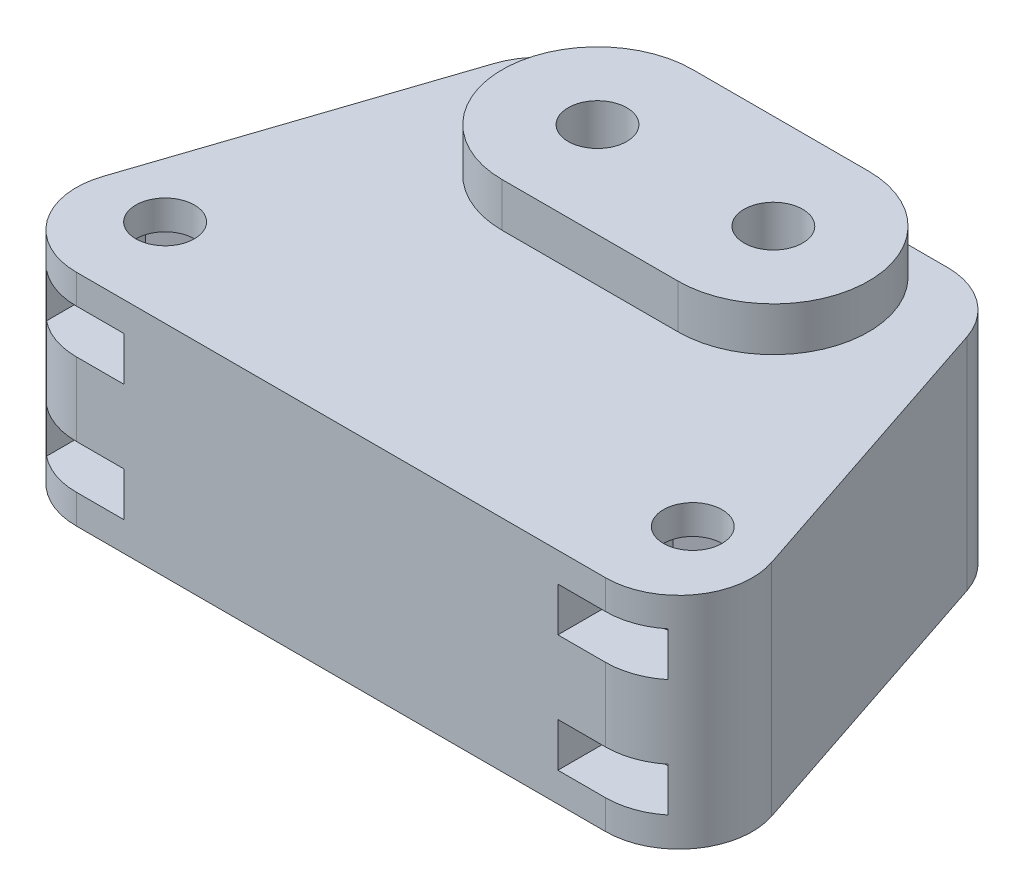
from build123d import *

# Parameters (mm, degrees)
SKETCH1_R           = 2
BOSS_EXTRUDE1_DEPTH = 15
SKETCH2_R           = 2
BOSS_EXTRUDE2_DEPTH = 3
SKETCH5_W           = 6.4
SKETCH5_H           = 3
CUT_EXTRUDE1_DEPTH  = 6.4
CUT_EXTRUDE2_DEPTH  = 3
CUT_EXTRUDE3_DEPTH  = 3
SKETCH8_W           = 6.4
SKETCH8_H           = 3
CUT_EXTRUDE4_DEPTH  = 6
CUT_EXTRUDE5_DEPTH  = 3
CUT_EXTRUDE6_DEPTH  = 3


with BuildPart() as part:
    # Sketch1 → Boss-Extrude1 (new body)
    with BuildSketch(Plane(origin=(0, 0, 0), x_dir=(1, 0, 0), z_dir=(0, 1, 0))):
        with BuildLine():
            Line((-18.062870566, 0), (18.062870566, 0))
            ThreePointArc((18.062870566, 0), (22.119081492, 2.076448577), (22.806287057, 6.58113883))
            Line((22.806287057, 6.58113883), (16.13962039, 26.58113883))
            ThreePointArc((16.13962039, 26.58113883), (14.319755323, 29.056210926), (11.3962039, 30))
            Line((11.3962039, 30), (-11.3962039, 30))
            ThreePointArc((-11.3962039, 30), (-14.319755323, 29.056210926), (-16.13962039, 26.58113883))
            Line((-16.13962039, 26.58113883), (-22.806287057, 6.58113883))
            ThreePointArc((-22.806287057, 6.58113883), (-22.119081492, 2.076448577), (-18.062870566, 0))
        make_face()
        with Locations((-18, 6)):
            Circle(SKETCH1_R, mode=Mode.SUBTRACT)
        with Locations((18, 6)):
            Circle(SKETCH1_R, mode=Mode.SUBTRACT)
        with Locations((6, 23.5)):
            Circle(SKETCH1_R, mode=Mode.SUBTRACT)
        with Locations((-6, 23.5)):
            Circle(SKETCH1_R, mode=Mode.SUBTRACT)
    extrude(amount=BOSS_EXTRUDE1_DEPTH)

    # Sketch2 → Boss-Extrude2 (add)
    with BuildSketch(Plane(origin=(0, 15, 0), x_dir=(1, 0, 0), z_dir=(0, 1, 0))):
        with BuildLine():
            Line((-6, 30), (6, 30))
            ThreePointArc((6, 30), (12.5, 23.5), (6, 17))
            Line((6, 17), (-6, 17))
            ThreePointArc((-6, 17), (-12.5, 23.5), (-6, 30))
        make_face()
        with Locations((-6, 23.5)):
            Circle(SKETCH2_R, mode=Mode.SUBTRACT)
        with Locations((6, 23.5)):
            Circle(SKETCH2_R, mode=Mode.SUBTRACT)
    extrude(amount=BOSS_EXTRUDE2_DEPTH)

    # Sketch5 → Cut-Extrude1 (cut)
    with BuildSketch(Plane(origin=(0, 0, -30), x_dir=(-1, 0, 0), z_dir=(0, 0, -1))):
        with Locations((6, 12.5)):
            Rectangle(SKETCH5_W, SKETCH5_H)
        with Locations((-6, 12.5)):
            Rectangle(SKETCH5_W, SKETCH5_H)
        with Locations((-6, 3.5)):
            Rectangle(SKETCH5_W, SKETCH5_H)
        with Locations((6, 3.5)):
            Rectangle(SKETCH5_W, SKETCH5_H)
    extrude(amount=-CUT_EXTRUDE1_DEPTH, mode=Mode.SUBTRACT)

    # Sketch6 → Cut-Extrude2 (cut)
    with BuildSketch(Plane(origin=(0, 11, 0), x_dir=(1, 0, 0), z_dir=(0, 1, 0))):
        Polygon((9.2, 25.347520861), (6, 27.195041723), (2.8, 25.347520861), (2.8, 21.652479139), (6, 19.804958277), (9.2, 21.652479139), align=None)
        Polygon((-2.8, 25.347520861), (-6, 27.195041723), (-9.2, 25.347520861), (-9.2, 21.652479139), (-6, 19.804958277), (-2.8, 21.652479139), align=None)
    extrude(amount=CUT_EXTRUDE2_DEPTH, mode=Mode.SUBTRACT)

    # Sketch7 → Cut-Extrude3 (cut)
    with BuildSketch(Plane(origin=(0, 2, 0), x_dir=(1, 0, 0), z_dir=(0, 1, 0))):
        Polygon((9.2, 25.347520861), (6, 27.195041723), (2.8, 25.347520861), (2.8, 21.652479139), (6, 19.804958277), (9.2, 21.652479139), align=None)
        Polygon((-6, 19.804958277), (-2.8, 21.652479139), (-2.8, 25.347520861), (-6, 27.195041723), (-9.2, 25.347520861), (-9.2, 21.652479139), align=None)
    extrude(amount=CUT_EXTRUDE3_DEPTH, mode=Mode.SUBTRACT)

    # Sketch8 → Cut-Extrude4 (cut)
    with BuildSketch(Plane.XY):
        with Locations((18, 11.5)):
            Rectangle(SKETCH8_W, SKETCH8_H)
        with Locations((-18, 11.5)):
            Rectangle(SKETCH8_W, SKETCH8_H)
        with Locations((-18, 3.5)):
            Rectangle(SKETCH8_W, SKETCH8_H)
        with Locations((18, 3.5)):
            Rectangle(SKETCH8_W, SKETCH8_H)
    extrude(amount=-CUT_EXTRUDE4_DEPTH, mode=Mode.SUBTRACT)

    # Sketch9 → Cut-Extrude5 (cut)
    with BuildSketch(Plane(origin=(0, 10, 0), x_dir=(1, 0, 0), z_dir=(0, 1, 0))):
        Polygon((21.2, 4.152479139), (21.2, 7.847520861), (18, 9.695041723), (14.8, 7.847520861), (14.8, 4.152479139), (18, 2.304958277), align=None)
        Polygon((-14.8, 4.152479139), (-14.8, 7.847520861), (-18, 9.695041723), (-21.2, 7.847520861), (-21.2, 4.152479139), (-18, 2.304958277), align=None)
    extrude(amount=CUT_EXTRUDE5_DEPTH, mode=Mode.SUBTRACT)

    # Sketch10 → Cut-Extrude6 (cut)
    with BuildSketch(Plane(origin=(0, 2, 0), x_dir=(1, 0, 0), z_dir=(0, 1, 0))):
        Polygon((21.2, 4.152479139), (21.2, 7.847520861), (18, 9.695041723), (14.8, 7.847520861), (14.8, 4.152479139), (18, 2.304958277), align=None)
        Polygon((-21.2, 4.152479139), (-18, 2.304958277), (-14.8, 4.152479139), (-14.8, 7.847520861), (-18, 9.695041723), (-21.2, 7.847520861), align=None)
    extrude(amount=CUT_EXTRUDE6_DEPTH, mode=Mode.SUBTRACT)


solid = part.part
